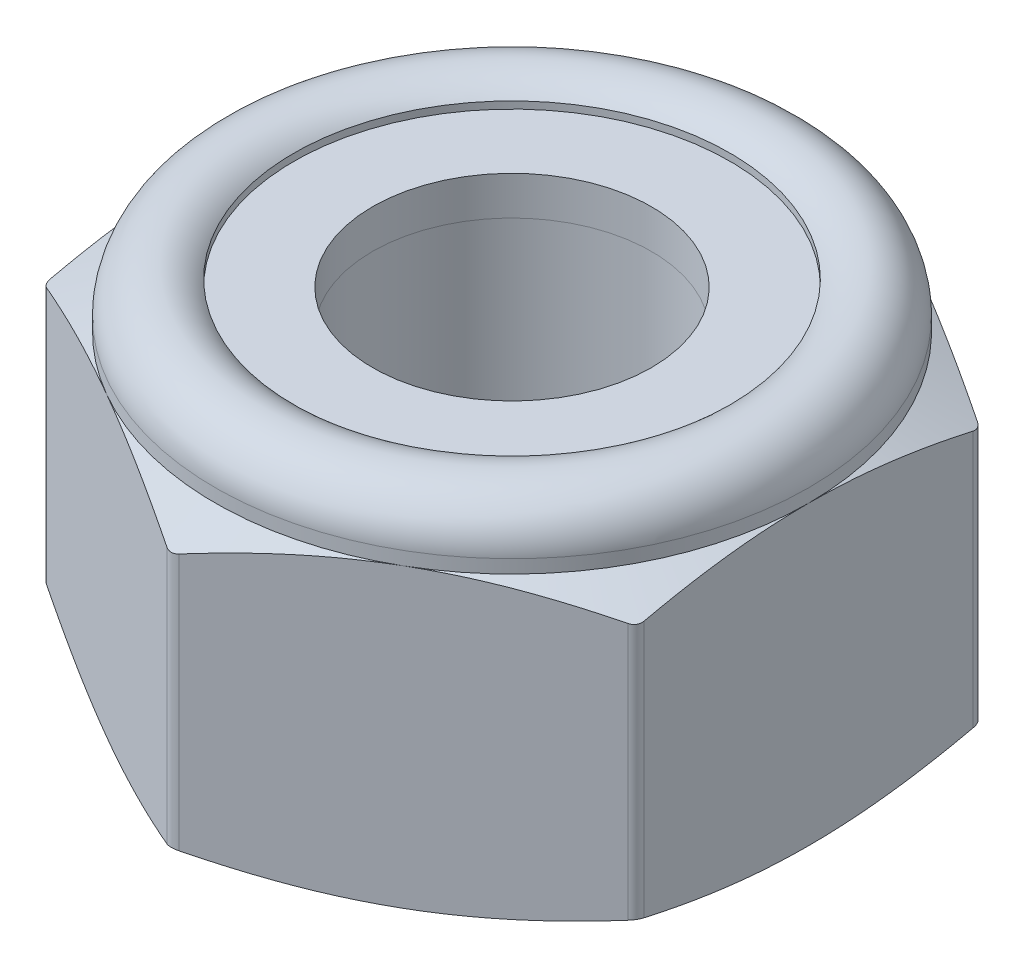
from build123d import *

# Parameters (mm, degrees)
SKETCH2_R                = 2.350480947
BOSS_EXTRUDE1_DEPTH      = 3
BOSS_EXTRUDE1_DEPTH_BACK = 3
FILLET1_R                = 0.2
SKETCH4_W                = 1.324759527
SKETCH4_H                = 0.652707199


with BuildPart() as part:
    # Sketch2 → Boss-Extrude1 (new body, two sides)
    with BuildSketch(Plane(origin=(0, 0, 0), x_dir=(1, 0, 0), z_dir=(0, 1, 0))) as boss_extrude1_sk:
        Polygon((0, 5.773502692), (-5, 2.886751346), (-5, -2.886751346), (0, -5.773502692), (5, -2.886751346), (5, 2.886751346), align=None)
        Circle(SKETCH2_R, mode=Mode.SUBTRACT)
    extrude(amount=BOSS_EXTRUDE1_DEPTH)
    extrude(boss_extrude1_sk.sketch, amount=-BOSS_EXTRUDE1_DEPTH_BACK)

    # Fillet1
    fillet1_edges = [part.edges().sort_by_distance(p)[0] for p in [
        (5, 0, -2.886751346),
        (5, 0, 2.886751346),
        (0, 0, 5.773502692),
        (-5, 0, 2.886751346),
        (-5, 0, -2.886751346),
        (0, 0, -5.773502692),
    ]]
    fillet(fillet1_edges, radius=FILLET1_R)

    # Sketch3 → Cut-Revolve2 (revolve, cut)
    with BuildSketch(Plane(origin=(0, 0, 0), x_dir=(0, 0, -1), z_dir=(1, 0, 0))):
        with BuildLine():
            Line((5.773502692, 2), (5.773502692, 4))
            Line((5.773502692, 4), (2.350480947, 4))
            Line((2.350480947, 4), (2.350480947, 2))
            Line((2.350480947, 2), (3.675240474, 2))
            Line((3.675240474, 2), (3.675240474, 2.772707199))
            ThreePointArc((3.675240474, 2.772707199), (4.520946192, 2.940928526), (5, 2.223973836))
            Line((5, 2.223973836), (5, 2))
            Line((5, 2), (5.773502692, 1.639309771))
            Line((5.773502692, 1.639309771), (5.773502692, 2))
        make_face()
        Polygon((5, -3), (5.773502692, -2.639309771), (5.773502692, -3), align=None)
        Polygon((2.350480947, -3), (2.350480947, -2.4), (2.950480947, -3), align=None)
    revolve(axis=Axis((0, -3, 0), (0, 1, 0)), mode=Mode.SUBTRACT)


with BuildPart() as body_2:
    # Sketch4 → Revolve1 (revolve)
    with BuildSketch(Plane(origin=(0, 0, 0), x_dir=(0, 0, -1), z_dir=(1, 0, 0))):
        with Locations((-3.012860711, 2.326353599)):
            Rectangle(SKETCH4_W, SKETCH4_H)
    revolve(axis=Axis((0, -3, 0), (0, 1, 0)))


solid = Compound([part.part, body_2.part])
